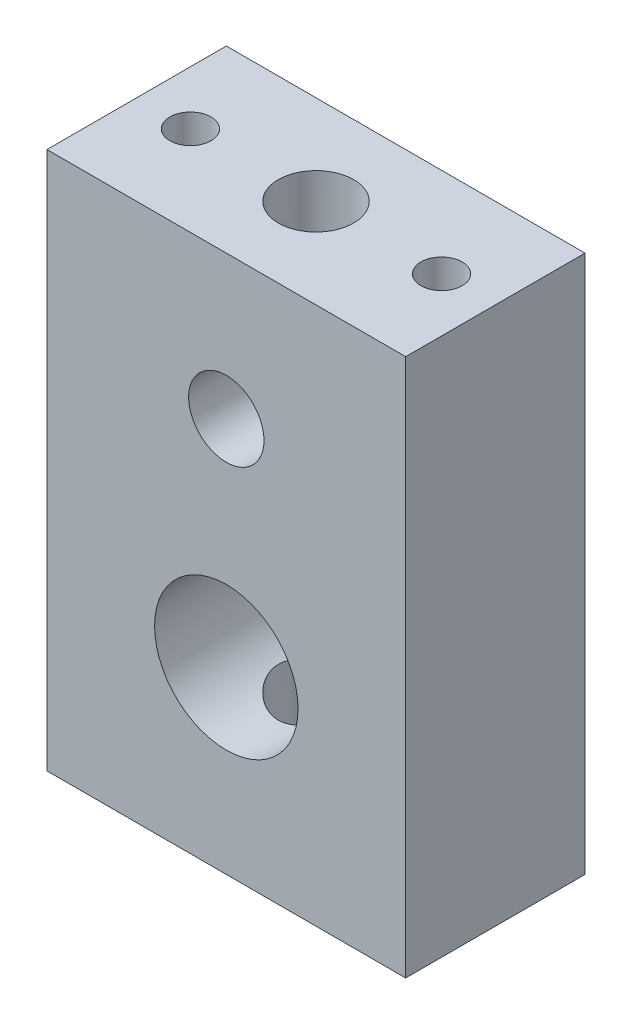
from build123d import *

# Parameters (mm, degrees)
SKETCH1_W           = 20
SKETCH1_H           = 30
SKETCH1_R           = 4
SKETCH1_R_2         = 2.1
BOSS_EXTRUDE1_DEPTH = 10
SKETCH2_R           = 1.15
SKETCH2_R_2         = 2.1
CUT_EXTRUDE1_DEPTH  = 31


with BuildPart() as part:
    # Sketch1 → Boss-Extrude1 (new body)
    with BuildSketch(Plane.XY):
        with Locations((10, 15)):
            Rectangle(SKETCH1_W, SKETCH1_H)
        with Locations((10, 10)):
            Circle(SKETCH1_R, mode=Mode.SUBTRACT)
        with Locations((10, 22)):
            Circle(SKETCH1_R_2, mode=Mode.SUBTRACT)
    extrude(amount=BOSS_EXTRUDE1_DEPTH)

    # Sketch2 → Cut-Extrude1 (cut, through all)
    with BuildSketch(Plane(origin=(0, 30, 0), x_dir=(1, 0, 0), z_dir=(0, 1, 0))):
        with Locations((3, -5)):
            Circle(SKETCH2_R)
        with Locations((17, -5)):
            Circle(SKETCH2_R)
        with Locations((10, -5)):
            Circle(SKETCH2_R_2)
    extrude(amount=-CUT_EXTRUDE1_DEPTH, mode=Mode.SUBTRACT)


solid = part.part
